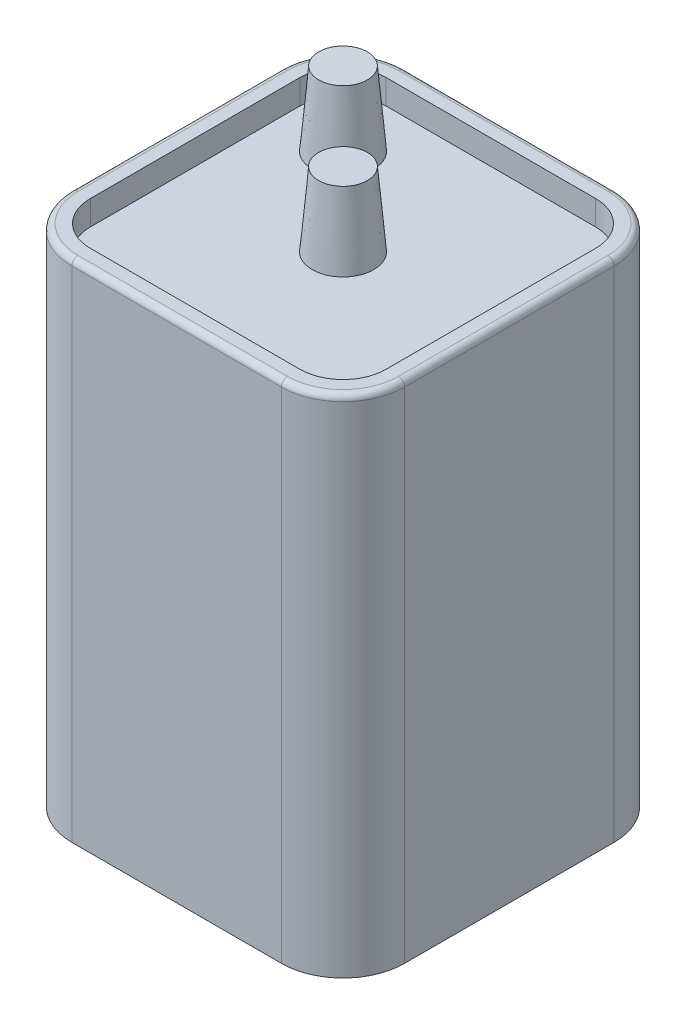
from build123d import *

# Parameters (mm, degrees)
SKETCH1_W          = 68.58
SKETCH1_H          = 68.58
BASE_EXTRUDE_DEPTH = 104.14
SIDE_FILLETS_R     = 12.7
TOP_CUT_DEPTH      = 5.08
TOP_FACE_FILLET_R  = 1.27
SKETCH_TERMINALS_R = 6.35
TERMINALS_DEPTH    = 15.24
TERMINALS_TAPER    = 5


with BuildPart() as part:
    # Sketch1 → Base Extrude (new body)
    with BuildSketch(Plane(origin=(0, 0, 0), x_dir=(1, 0, 0), z_dir=(0, 1, 0))):
        Rectangle(SKETCH1_W, SKETCH1_H)
    extrude(amount=BASE_EXTRUDE_DEPTH)

    # Side Fillets
    side_fillets_edges = [part.edges().sort_by_distance(p)[0] for p in [
        (34.29, 52.07, 34.29),
        (-34.29, 52.07, 34.29),
        (-34.29, 52.07, -34.29),
        (34.29, 52.07, -34.29),
    ]]
    fillet(side_fillets_edges, radius=SIDE_FILLETS_R)

    # Sketch2 → Top Cut (cut)
    with BuildSketch(Plane(origin=(0, 104.14, 0), x_dir=(1, 0, 0), z_dir=(0, 1, 0))):
        with BuildLine():
            Line((-30.48, 21.59), (-30.48, -21.59))
            ThreePointArc((-30.48, -21.59), (-27.876179285, -27.876179285), (-21.59, -30.48))
            Line((-21.59, -30.48), (21.59, -30.48))
            ThreePointArc((21.59, -30.48), (27.876179285, -27.876179285), (30.48, -21.59))
            Line((30.48, -21.59), (30.48, 21.59))
            ThreePointArc((30.48, 21.59), (27.876179285, 27.876179285), (21.59, 30.48))
            Line((21.59, 30.48), (-21.59, 30.48))
            ThreePointArc((-21.59, 30.48), (-27.876179285, 27.876179285), (-30.48, 21.59))
        make_face()
    extrude(amount=-TOP_CUT_DEPTH, mode=Mode.SUBTRACT)

    # Top Face Fillet
    top_face_fillet_edges = [part.edges().sort_by_distance(p)[0] for p in [
        (0, 104.14, 34.29),
        (-34.29, 104.14, 0),
        (34.29, 104.14, 0),
        (0, 104.14, -34.29),
        (30.570256121, 104.14, 30.570256121),
        (30.570256121, 104.14, -30.570256121),
        (-30.570256121, 104.14, -30.570256121),
        (-30.570256121, 104.14, 30.570256121),
    ]]
    fillet(top_face_fillet_edges, radius=TOP_FACE_FILLET_R)

    # Sketch-TERMINALS → Terminals (add)
    with BuildSketch(Plane(origin=(0, 99.06, 0), x_dir=(1, 0, 0), z_dir=(0, 1, 0))):
        Circle(SKETCH_TERMINALS_R)
        with Locations((-17.960512242, 17.960512242)):
            Circle(SKETCH_TERMINALS_R)
    extrude(amount=TERMINALS_DEPTH, taper=TERMINALS_TAPER)


solid = part.part
